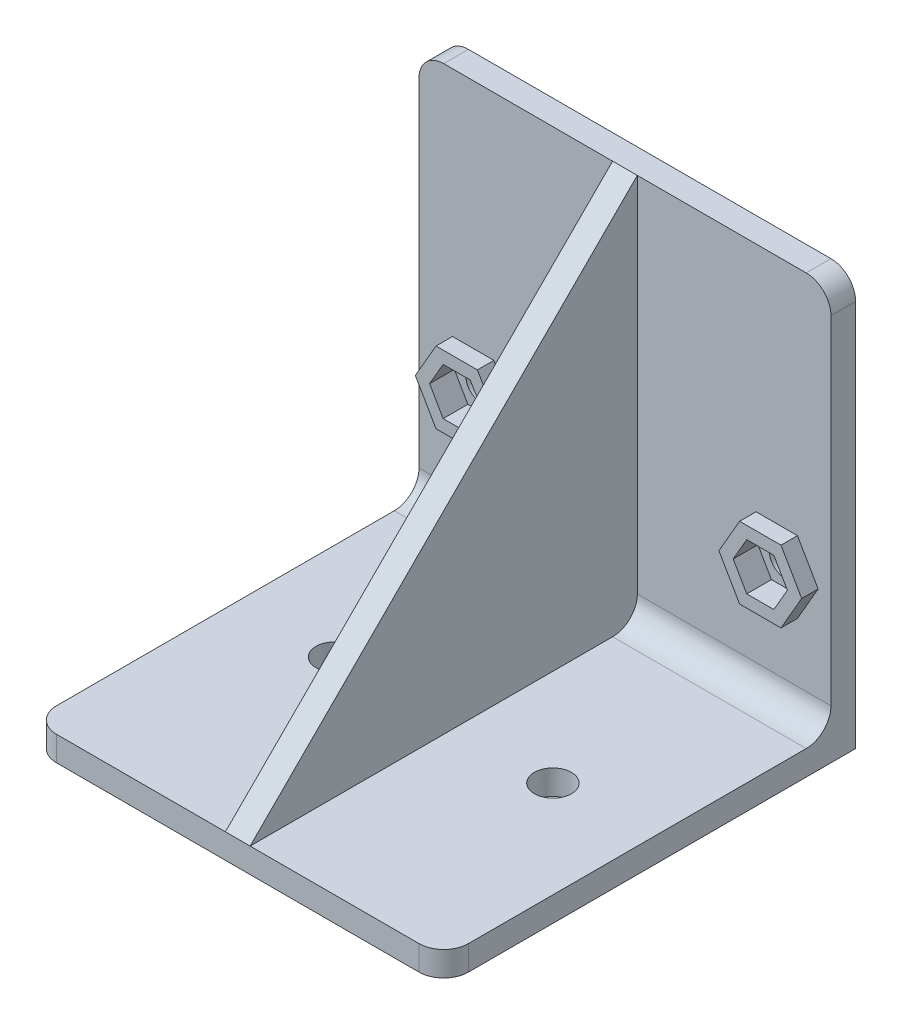
from build123d import *

# Parameters (mm, degrees)
SKETCH1_W           = 50
SKETCH1_H           = 50
BOSS_EXTRUDE1_DEPTH = 3
SKETCH2_W           = 50
SKETCH2_H           = 3
BOSS_EXTRUDE2_DEPTH = 47
BOSS_EXTRUDE3_DEPTH = 1.5
CUT_EXTRUDE1_REACH  = 52
SKETCH4_R           = 1.9
SKETCH4_W           = 7.5
SKETCH4_H           = 7.5
FILLET1_R           = 1
CUT_EXTRUDE3_DEPTH  = 1
BOSS_EXTRUDE4_DEPTH = 2
FILLET3_R           = 3
CUT_EXTRUDE4_REACH  = 5
SKETCH8_R           = 2.25


with BuildPart() as part:
    # Sketch1 → Boss-Extrude1 (new body)
    with BuildSketch(Plane(origin=(0, 0, 0), x_dir=(1, 0, 0), z_dir=(0, 1, 0))):
        Rectangle(SKETCH1_W, SKETCH1_H)
    extrude(amount=BOSS_EXTRUDE1_DEPTH)

    # Sketch2 → Boss-Extrude2 (add)
    with BuildSketch(Plane(origin=(0, 3, 0), x_dir=(1, 0, 0), z_dir=(0, 1, 0))):
        with Locations((0, 23.5)):
            Rectangle(SKETCH2_W, SKETCH2_H)
    extrude(amount=BOSS_EXTRUDE2_DEPTH)

    # Sketch3 → Boss-Extrude3 (add, symmetric)
    with BuildSketch(Plane(origin=(0, 0, 0), x_dir=(0, 0, -1), z_dir=(1, 0, 0))):
        Polygon((-25, 3), (22, 50), (22, 3), align=None)
    extrude(amount=BOSS_EXTRUDE3_DEPTH, both=True)

    # Sketch4 → Cut-Extrude1 (cut, up to next)
    with BuildSketch(Plane(origin=(0, 0, -25), x_dir=(-1, 0, 0), z_dir=(0, 0, -1)), mode=Mode.PRIVATE) as cut_extrude1_sk1:
        with Locations((-18.425, 17.5)):
            Circle(SKETCH4_R)
    cut_extrude1_tool1 = extrude(cut_extrude1_sk1.sketch, amount=-CUT_EXTRUDE1_REACH, mode=Mode.PRIVATE) & part.part
    add(cut_extrude1_tool1.solids().sort_by_distance((18.425, 17.5, -25))[0], mode=Mode.SUBTRACT)
    # Sketch4 → Cut-Extrude1 (cut, up to next)
    with BuildSketch(Plane(origin=(0, 0, -25), x_dir=(-1, 0, 0), z_dir=(0, 0, -1)), mode=Mode.PRIVATE) as cut_extrude1_sk2:
        with Locations((18.425, 17.5)):
            Circle(SKETCH4_R)
    cut_extrude1_tool2 = extrude(cut_extrude1_sk2.sketch, amount=-CUT_EXTRUDE1_REACH, mode=Mode.PRIVATE) & part.part
    add(cut_extrude1_tool2.solids().sort_by_distance((-18.425, 17.5, -25))[0], mode=Mode.SUBTRACT)
    # Sketch4 → Cut-Extrude1 (cut, up to next)
    with BuildSketch(Plane(origin=(0, 0, -25), x_dir=(-1, 0, 0), z_dir=(0, 0, -1)), mode=Mode.PRIVATE) as cut_extrude1_sk3:
        with Locations((9.5, 15)):
            Rectangle(SKETCH4_W, SKETCH4_H)
    cut_extrude1_tool3 = extrude(cut_extrude1_sk3.sketch, amount=-CUT_EXTRUDE1_REACH, mode=Mode.PRIVATE) & part.part
    add(cut_extrude1_tool3.solids().sort_by_distance((-9.5, 15, -25))[0], mode=Mode.SUBTRACT)

    # Fillet1
    fillet1_edges = [part.edges().sort_by_distance(p)[0] for p in [
        (-13.25, 18.75, -23.5),
        (-13.25, 11.25, -23.5),
        (-5.75, 11.25, -23.5),
        (-5.75, 18.75, -23.5),
    ]]
    fillet(fillet1_edges, radius=FILLET1_R)

    # Sketch6 → Cut-Extrude3 (cut)
    with BuildSketch(Plane.XY.offset(-22)):
        Polygon((16.779551733, 14.65), (20.070448267, 14.65), (21.715896534, 17.5), (20.070448267, 20.35), (16.779551733, 20.35), (15.134103466, 17.5), align=None)
        Polygon((-20.070448267, 14.65), (-21.715896534, 17.5), (-20.070448267, 20.35), (-16.779551733, 20.35), (-15.134103466, 17.5), (-16.779551733, 14.65), align=None)
    extrude(amount=-CUT_EXTRUDE3_DEPTH, mode=Mode.SUBTRACT)

    # Sketch7 → Boss-Extrude4 (add)
    with BuildSketch(Plane.XY.offset(-22)):
        Polygon((-15.913526329, 13.15), (-13.402052658, 17.5), (-15.913526329, 21.85), (-20.936473671, 21.85), (-23.447947342, 17.5), (-20.936473671, 13.15), align=None)
        Polygon((-16.779551733, 14.65), (-15.134103466, 17.5), (-16.779551733, 20.35), (-20.070448267, 20.35), (-21.715896534, 17.5), (-20.070448267, 14.65), align=None, mode=Mode.SUBTRACT)
        Polygon((13.402052658, 17.5), (15.913526329, 13.15), (20.936473671, 13.15), (23.447947342, 17.5), (20.936473671, 21.85), (15.913526329, 21.85), align=None)
        Polygon((16.779551733, 14.65), (20.070448267, 14.65), (21.715896534, 17.5), (20.070448267, 20.35), (16.779551733, 20.35), (15.134103466, 17.5), align=None, mode=Mode.SUBTRACT)
    extrude(amount=BOSS_EXTRUDE4_DEPTH)

    # Fillet3
    fillet3_edges = [part.edges().sort_by_distance(p)[0] for p in [
        (-13.25, 3, -22),
        (-25, 50, -23.5),
        (25, 50, -23.5),
        (13.25, 3, -22),
        (25, 1.5, 25),
        (-25, 1.5, 25),
    ]]
    fillet(fillet3_edges, radius=FILLET3_R)

    # Sketch8 → Cut-Extrude4 (cut, up to next)
    with BuildSketch(Plane(origin=(0, 3, 0), x_dir=(1, 0, 0), z_dir=(0, 1, 0)), mode=Mode.PRIVATE) as cut_extrude4_sk1:
        with Locations((-13.25, 0)):
            Circle(SKETCH8_R)
    cut_extrude4_tool1 = extrude(cut_extrude4_sk1.sketch, amount=-CUT_EXTRUDE4_REACH, mode=Mode.PRIVATE) & part.part
    add(cut_extrude4_tool1.solids().sort_by_distance((-13.25, 3, 0))[0], mode=Mode.SUBTRACT)
    # Sketch8 → Cut-Extrude4 (cut, up to next)
    with BuildSketch(Plane(origin=(0, 3, 0), x_dir=(1, 0, 0), z_dir=(0, 1, 0)), mode=Mode.PRIVATE) as cut_extrude4_sk2:
        with Locations((13.25, 0)):
            Circle(SKETCH8_R)
    cut_extrude4_tool2 = extrude(cut_extrude4_sk2.sketch, amount=-CUT_EXTRUDE4_REACH, mode=Mode.PRIVATE) & part.part
    add(cut_extrude4_tool2.solids().sort_by_distance((13.25, 3, 0))[0], mode=Mode.SUBTRACT)


solid = part.part
